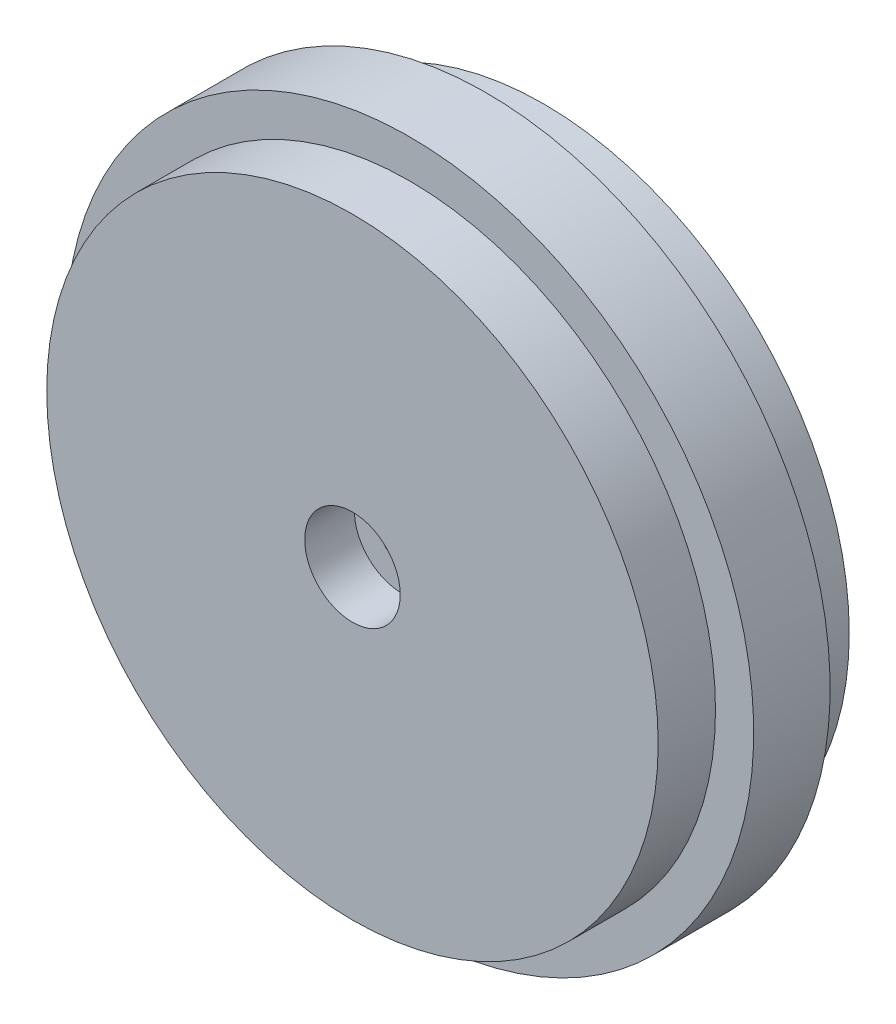
from build123d import *

# Parameters (mm, degrees)
ESQUISSE1_R                                        = 14.5
BOSS_EXTRU_1_DEPTH                                 = 10
BOSS_EXTRU_2_START                                 = 1
ESQUISSE2_R                                        = 16.5
BOSS_EXTRU_2_DEPTH                                 = 8
ESQUISSE6_R                                        = 13.5
ENL_V_MAT_EXTRU_4_DEPTH                            = 1
CHAMBRAGE_POUR_VIS_T_TE_RONDE_BOMB_E_M_D           = 2.4
CHAMBRAGE_POUR_VIS_T_TE_RONDE_BOMB_E_M_CBORE_D     = 5
CHAMBRAGE_POUR_VIS_T_TE_RONDE_BOMB_E_M_CBORE_DEPTH = 1.6
ESQUISSE13_R                                       = 13.5
ESQUISSE13_R_2                                     = 4.2
ENL_V_MAT_EXTRU_7_DEPTH                            = 7
ENL_V_MAT_EXTRU_8_DEPTH                            = 7
BOSS_EXTRUDE2_START                                = -9
SKETCH2_R                                          = 16.5
SKETCH2_R_2                                        = 14.5
BOSS_EXTRUDE2_DEPTH                                = 10
SKETCH3_R                                          = 22.5
SKETCH3_R_2                                        = 16.5
BOSS_EXTRUDE3_DEPTH                                = 10
FILLET1_R                                          = 1
BOSS_EXTRUDE4_DEPTH                                = 0.5
CIRPATTERN1_COUNT                                  = 70
SKETCH5_R                                          = 40
SKETCH5_R_2                                        = 16
CUT_EXTRUDE1_DEPTH                                 = 20
BOSS_EXTRUDE5_START                                = -3
SKETCH6_R                                          = 18
SKETCH6_R_2                                        = 16
BOSS_EXTRUDE5_DEPTH                                = 4
SKETCH8_R                                          = 13.5
SKETCH8_R_2                                        = 2.5
BOSS_EXTRUDE6_DEPTH                                = 1


with BuildPart() as part:
    # Esquisse1 → Boss.-Extru.1 (new body)
    with BuildSketch(Plane.XY):
        Circle(ESQUISSE1_R)
    extrude(amount=BOSS_EXTRU_1_DEPTH)

    # Esquisse2 → Boss.-Extru.2 (add)
    with BuildSketch(Plane.XY.offset(BOSS_EXTRU_2_START)):
        Circle(ESQUISSE2_R)
    extrude(amount=BOSS_EXTRU_2_DEPTH)

    # Esquisse6 → Enlèv. mat.-Extru.4 (cut)
    with BuildSketch(Plane.XY.offset(10)):
        Circle(ESQUISSE6_R)
    extrude(amount=-ENL_V_MAT_EXTRU_4_DEPTH, mode=Mode.SUBTRACT)

    # Chambrage pour vis à tête ronde bombée M21 (through all)
    with Locations(Plane.XY.offset(9)):
        with Locations((0, 0)):
            CounterBoreHole(CHAMBRAGE_POUR_VIS_T_TE_RONDE_BOMB_E_M_D / 2, CHAMBRAGE_POUR_VIS_T_TE_RONDE_BOMB_E_M_CBORE_D / 2, CHAMBRAGE_POUR_VIS_T_TE_RONDE_BOMB_E_M_CBORE_DEPTH)

    # Esquisse13 → Enlèv. mat.-Extru.7 (cut)
    with BuildSketch(Plane(origin=(0, 0, 0), x_dir=(-1, 0, 0), z_dir=(0, 0, -1))):
        Circle(ESQUISSE13_R)
        Circle(ESQUISSE13_R_2, mode=Mode.SUBTRACT)
    extrude(amount=-ENL_V_MAT_EXTRU_7_DEPTH, mode=Mode.SUBTRACT)

    # Esquisse15 → Enlèv. mat.-Extru.8 (cut)
    with BuildSketch(Plane(origin=(0, 0, 0), x_dir=(-1, 0, 0), z_dir=(0, 0, -1))):
        with BuildLine():
            Line((-2.15, 2.092247595), (-2.15, -2.092247595))
            ThreePointArc((-2.15, -2.092247595), (0, -3), (2.15, -2.092247595))
            Line((2.15, -2.092247595), (2.15, 2.092247595))
            ThreePointArc((2.15, 2.092247595), (0, 3), (-2.15, 2.092247595))
        make_face()
    extrude(amount=-ENL_V_MAT_EXTRU_8_DEPTH, mode=Mode.SUBTRACT)

    # Sketch2 → Boss-Extrude2 (add)
    with BuildSketch(Plane(origin=(0, 0, 1), x_dir=(-1, 0, 0), z_dir=(0, 0, -1)).offset(BOSS_EXTRUDE2_START)):
        Circle(SKETCH2_R)
        Circle(SKETCH2_R_2, mode=Mode.SUBTRACT)
    extrude(amount=BOSS_EXTRUDE2_DEPTH)

    # Sketch3 → Boss-Extrude3 (add)
    with BuildSketch(Plane(origin=(0, 0, 0), x_dir=(-1, 0, 0), z_dir=(0, 0, -1))):
        Circle(SKETCH3_R)
        Circle(SKETCH3_R_2, mode=Mode.SUBTRACT)
    extrude(amount=-BOSS_EXTRUDE3_DEPTH)

    # Fillet1
    fillet1_edges = [part.edges().sort_by_distance(p)[0] for p in [
        (22.5, 0, 10),
        (22.5, 0, 0),
    ]]
    fillet(fillet1_edges, radius=FILLET1_R)

    # Sketch4 → Boss-Extrude4 (add, symmetric)
    with BuildSketch(Plane(origin=(0, 0, 0), x_dir=(0, 0, -1), z_dir=(1, 0, 0))):
        with BuildLine():
            Line((-9, 22.5), (-9, 18))
            Line((-9, 18), (-1, 18))
            Line((-1, 18), (-1, 22.5))
            ThreePointArc((-1, 22.5), (-5, 23.4), (-9, 22.5))
        make_face()
    boss_extrude4 = extrude(amount=BOSS_EXTRUDE4_DEPTH, both=True)

    # CirPattern1: Boss-Extrude4 ×70 about axis
    cirpattern1_axis = Axis((0, 0, 0), (0, 0, 1))
    for i in range(1, CIRPATTERN1_COUNT):
        add(boss_extrude4.rotate(cirpattern1_axis, i * 360 / CIRPATTERN1_COUNT))

    # Sketch5 → Cut-Extrude1 (cut)
    with BuildSketch(Plane(origin=(0, 0, 0), x_dir=(-1, 0, 0), z_dir=(0, 0, -1))):
        Circle(SKETCH5_R)
        Circle(SKETCH5_R_2, mode=Mode.SUBTRACT)
    extrude(amount=-CUT_EXTRUDE1_DEPTH, mode=Mode.SUBTRACT)

    # Sketch6 → Boss-Extrude5 (add)
    with BuildSketch(Plane(origin=(0, 0, 0), x_dir=(-1, 0, 0), z_dir=(0, 0, -1)).offset(BOSS_EXTRUDE5_START)):
        Circle(SKETCH6_R)
        Circle(SKETCH6_R_2, mode=Mode.SUBTRACT)
    extrude(amount=-BOSS_EXTRUDE5_DEPTH)

    # Sketch8 → Boss-Extrude6 (add)
    with BuildSketch(Plane.XY.offset(9)):
        Circle(SKETCH8_R)
        Circle(SKETCH8_R_2, mode=Mode.SUBTRACT)
    extrude(amount=BOSS_EXTRUDE6_DEPTH)


solid = part.part
